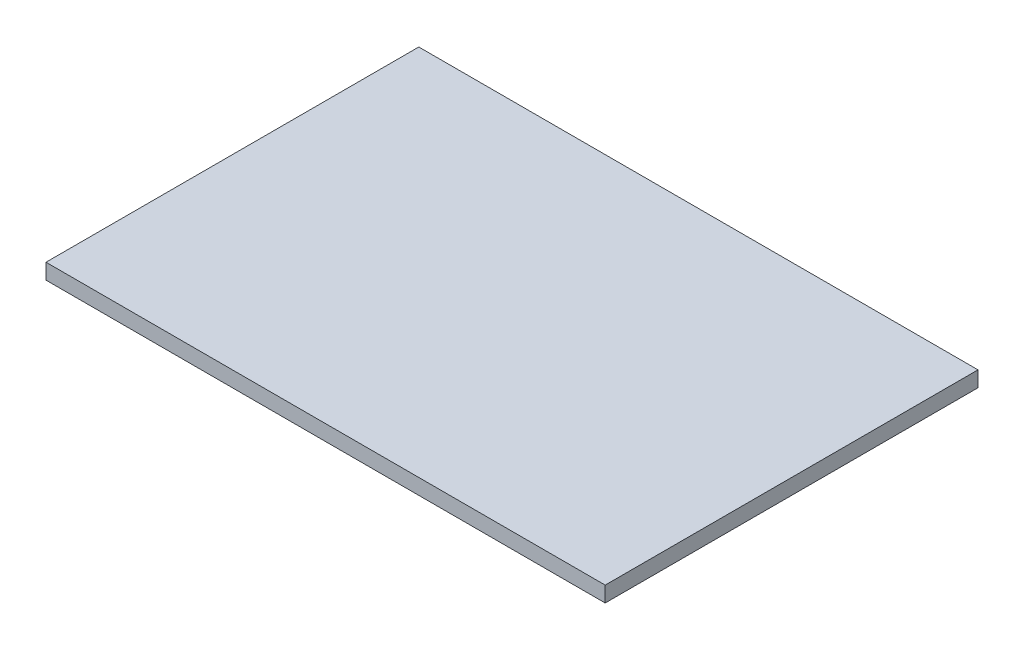
from build123d import *

# Parameters (mm, degrees)
SKETCH1_W           = 57.15
SKETCH1_H           = 38.1
BOSS_EXTRUDE1_DEPTH = 1.5875


with BuildPart() as part:
    # Sketch1 → Boss-Extrude1 (new body)
    with BuildSketch(Plane(origin=(0, 0, 0), x_dir=(1, 0, 0), z_dir=(0, 1, 0))):
        with Locations((28.575, 19.05)):
            Rectangle(SKETCH1_W, SKETCH1_H)
    extrude(amount=BOSS_EXTRUDE1_DEPTH)


solid = part.part
